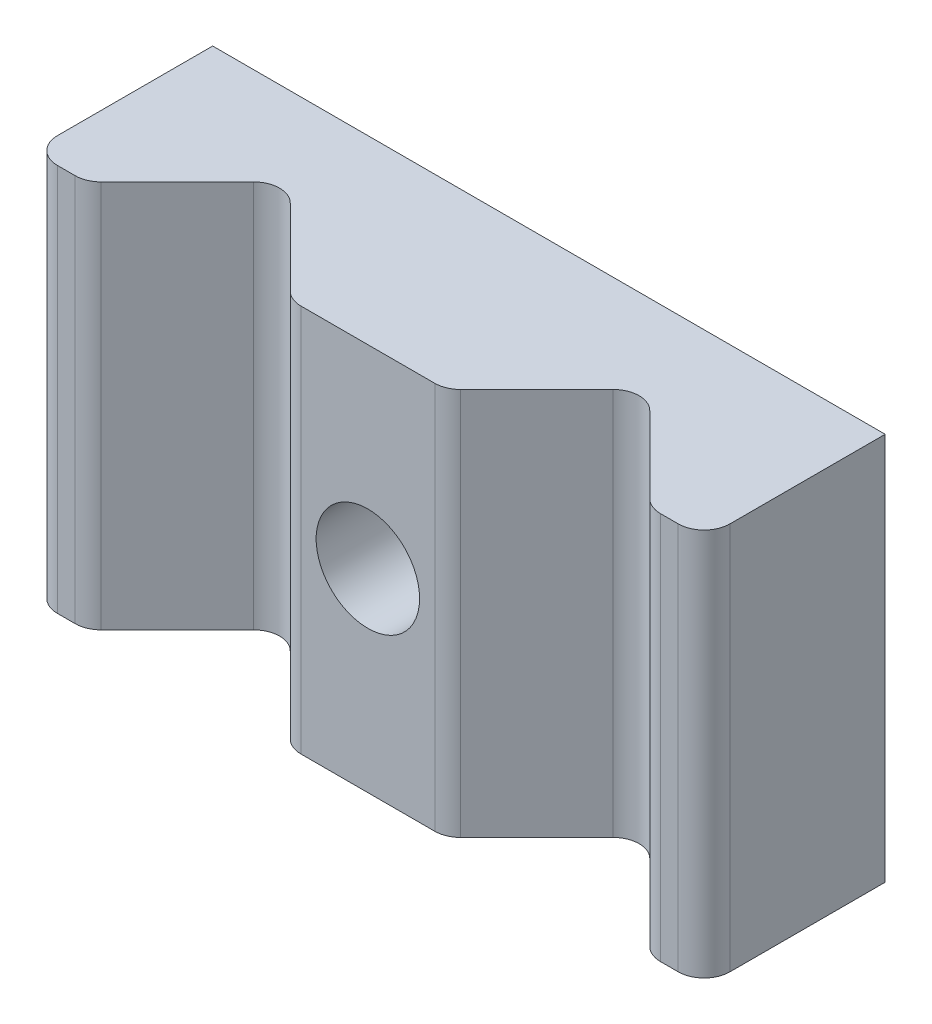
from build123d import *

# Parameters (mm, degrees)
SKETCH1_W           = 26
SKETCH1_H           = 15
SKETCH1_R           = 2
BOSS_EXTRUDE1_DEPTH = 7
CUT_EXTRUDE1_DEPTH  = 16
FILLET1_R           = 1


with BuildPart() as part:
    # Sketch1 → Boss-Extrude1 (new body)
    with BuildSketch(Plane.XY):
        with Locations((13, 7.5)):
            Rectangle(SKETCH1_W, SKETCH1_H)
        with Locations((13, 7.5)):
            Circle(SKETCH1_R, mode=Mode.SUBTRACT)
    extrude(amount=BOSS_EXTRUDE1_DEPTH)

    # Sketch2 → Cut-Extrude1 (cut, through all)
    with BuildSketch(Plane(origin=(0, 15, 0), x_dir=(1, 0, 0), z_dir=(0, 1, 0))):
        with BuildLine():
            Line((2.100252532, -7), (5.342893219, -3.757359313))
            ThreePointArc((5.342893219, -3.757359313), (6.05, -3.464466094), (6.757106781, -3.757359313))
            Line((6.757106781, -3.757359313), (9.999747468, -7))
            Line((9.999747468, -7), (2.100252532, -7))
        make_face()
        with BuildLine():
            Line((16.000252532, -7), (19.242893219, -3.757359313))
            ThreePointArc((19.242893219, -3.757359313), (19.95, -3.464466094), (20.657106781, -3.757359313))
            Line((20.657106781, -3.757359313), (23.899747468, -7))
            Line((23.899747468, -7), (16.000252532, -7))
        make_face()
    extrude(amount=-CUT_EXTRUDE1_DEPTH, mode=Mode.SUBTRACT)

    # Fillet1
    fillet1_edges = [part.edges().sort_by_distance(p)[0] for p in [
        (26, 7.5, 7),
        (9.999747468, 7.5, 7),
        (2.100252532, 7.5, 7),
        (23.899747468, 7.5, 7),
        (16.000252532, 7.5, 7),
        (0, 7.5, 7),
    ]]
    fillet(fillet1_edges, radius=FILLET1_R)


solid = part.part
